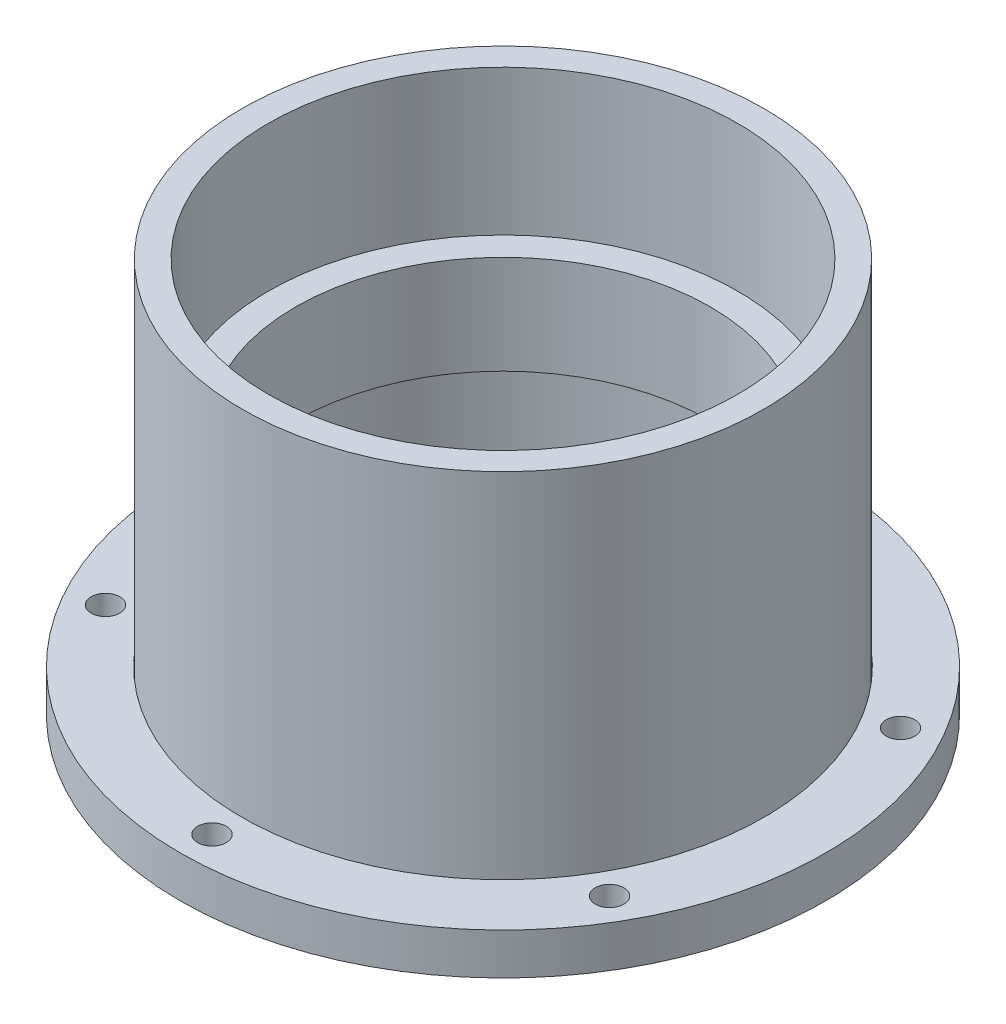
from build123d import *

# Parameters (mm, degrees)
SKETCH2_R           = 50.22
SKETCH2_R_2         = 45.22
BOSS_EXTRUDE1_DEPTH = 29
SKETCH3_R           = 50.22
SKETCH3_R_2         = 45.22
SKETCH3_R_3         = 39.97
BOSS_EXTRUDE2_DEPTH = 19
SKETCH4_R           = 50.22
SKETCH4_R_2         = 45.22
BOSS_EXTRUDE3_DEPTH = 28
SKETCH6_R           = 62.2
SKETCH6_R_2         = 50.32
SKETCH6_R_3         = 2.75
BOSS_EXTRUDE4_DEPTH = 8


with BuildPart() as part:
    # Sketch2 → Boss-Extrude1 (new body)
    with BuildSketch(Plane(origin=(0, 0, 0), x_dir=(1, 0, 0), z_dir=(0, 1, 0))):
        with Locations(Location((0, 0, 0), (0, 0, 90))):
            Circle(SKETCH2_R)
        with Locations(Location((0, 0, 0), (0, 0, 90))):
            Circle(SKETCH2_R_2, mode=Mode.SUBTRACT)
    extrude(amount=BOSS_EXTRUDE1_DEPTH)

    # Sketch3 → Boss-Extrude2 (add)
    with BuildSketch(Plane(origin=(0, 29, 0), x_dir=(1, 0, 0), z_dir=(0, 1, 0))):
        with Locations(Location((0, 0, 0), (0, 0, 90))):
            Circle(SKETCH3_R)
        with Locations(Location((0, 0, 0), (0, 0, 90))):
            Circle(SKETCH3_R_2, mode=Mode.SUBTRACT)
        with Locations(Location((0, 0, 0), (0, 0, 90))):
            Circle(SKETCH3_R_2)
        with Locations(Location((0, 0, 0), (0, 0, 270))):
            Circle(SKETCH3_R_3, mode=Mode.SUBTRACT)
    extrude(amount=BOSS_EXTRUDE2_DEPTH)

    # Sketch4 → Boss-Extrude3 (add)
    with BuildSketch(Plane(origin=(0, 48, 0), x_dir=(1, 0, 0), z_dir=(0, 1, 0))):
        with Locations(Location((0, 0, 0), (0, 0, 90))):
            Circle(SKETCH4_R)
        with Locations(Location((0, 0, 0), (0, 0, 90))):
            Circle(SKETCH4_R_2, mode=Mode.SUBTRACT)
    extrude(amount=BOSS_EXTRUDE3_DEPTH)


with BuildPart() as body_2:
    # Sketch6 → Boss-Extrude4 (new body)
    with BuildSketch(Plane.XZ):
        with Locations(Location((0, 0, 0), (0, 0, 270))):
            Circle(SKETCH6_R)
        with Locations(Location((0, 0, 0), (0, 0, 270))):
            Circle(SKETCH6_R_2, mode=Mode.SUBTRACT)
        with Locations(Location((0, 56.06, 0), (0, 0, 270))):
            Circle(SKETCH6_R_3, mode=Mode.SUBTRACT)
        with Locations(Location((-48.549384136, 28.03, 0), (0, 0, 270))):
            Circle(SKETCH6_R_3, mode=Mode.SUBTRACT)
        with Locations(Location((-48.549384136, -28.03, 0), (0, 0, 270))):
            Circle(SKETCH6_R_3, mode=Mode.SUBTRACT)
        with Locations(Location((48.549384136, 28.03, 0), (0, 0, 270))):
            Circle(SKETCH6_R_3, mode=Mode.SUBTRACT)
        with Locations(Location((48.549384136, -28.03, 0), (0, 0, 270))):
            Circle(SKETCH6_R_3, mode=Mode.SUBTRACT)
        with Locations(Location((0, -56.06, 0), (0, 0, 270))):
            Circle(SKETCH6_R_3, mode=Mode.SUBTRACT)
    extrude(amount=-BOSS_EXTRUDE4_DEPTH)


solid = Compound([part.part, body_2.part])
